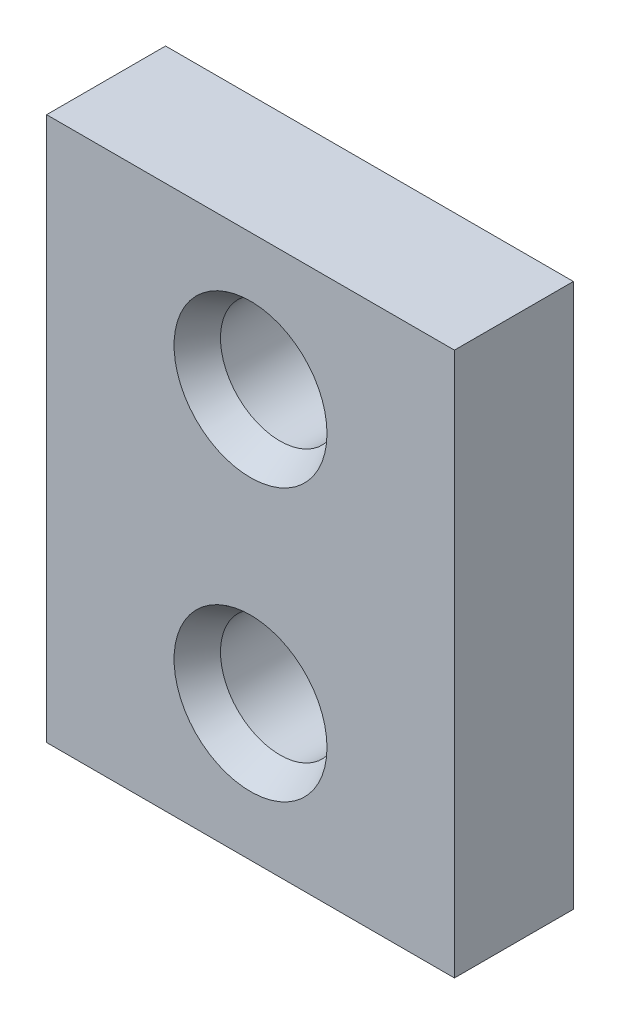
from build123d import *

# Parameters (mm, degrees)
SKETCH1_W           = 24
SKETCH1_H           = 32
BOSS_EXTRUDE1_DEPTH = 3.5
HOLE1_D             = 7
HOLE1_DEPTH         = 12
HOLE1_CSINK_D       = 9
HOLE1_CSINK_ANGLE   = 60


with BuildPart() as part:
    # Sketch1 → Boss-Extrude1 (new body, symmetric)
    with BuildSketch(Plane.XY):
        Rectangle(SKETCH1_W, SKETCH1_H)
    extrude(amount=BOSS_EXTRUDE1_DEPTH, both=True)

    # Hole1
    with Locations(Plane.XY.offset(3.5)):
        with Locations((0, 8), (0, -8)):
            CounterSinkHole(HOLE1_D / 2, HOLE1_CSINK_D / 2, depth=HOLE1_DEPTH, counter_sink_angle=HOLE1_CSINK_ANGLE)


solid = part.part
